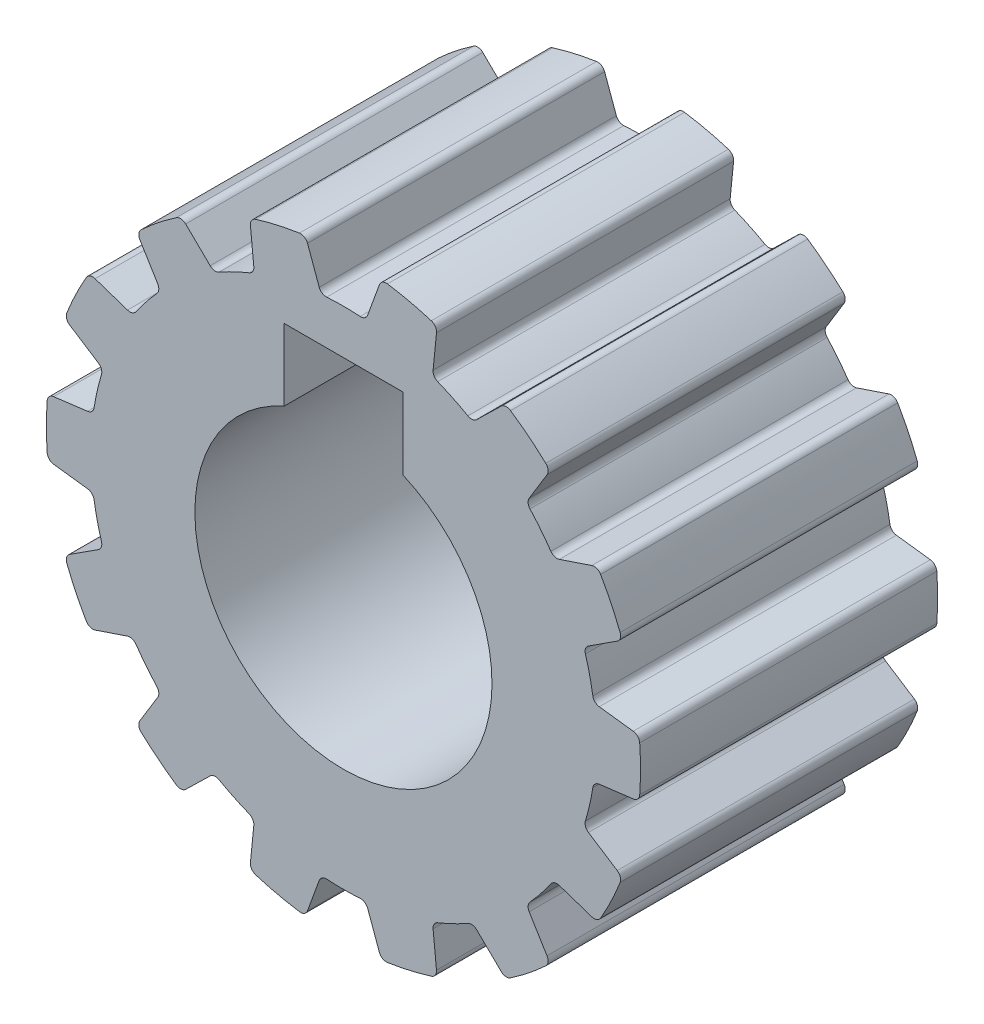
from build123d import *

# Parameters (mm, degrees)
SKETCH1_R           = 10
BOSS_EXTRUDE1_DEPTH = 10
CUT_EXTRUDE1_DEPTH  = 11
CIRPATTERN1_COUNT   = 14
FILLET1_R           = 0.25


with BuildPart() as part:
    # Sketch1 → Boss-Extrude1 (new body)
    with BuildSketch(Plane.XY):
        Circle(SKETCH1_R)
        with BuildLine():
            Line((-2, 7), (2, 7))
            Line((2, 7), (2, 4.582575695))
            ThreePointArc((2, 4.582575695), (0, -5), (-2, 4.582575695))
            Line((-2, 4.582575695), (-2, 7))
        make_face(mode=Mode.SUBTRACT)
    extrude(amount=BOSS_EXTRUDE1_DEPTH)

    # Sketch2 → Cut-Extrude1 (cut, through all)
    with BuildSketch(Plane.XY.offset(10)):
        with BuildLine():
            Line((0.75, 8.466847111), (1.278168411, 9.917977894))
            ThreePointArc((1.278168411, 9.917977894), (0, 10), (-1.278168411, 9.917977894))
            Line((-1.278168411, 9.917977894), (-0.75, 8.466847111))
            ThreePointArc((-0.75, 8.466847111), (0, 8.5), (0.75, 8.466847111))
        make_face()
    cut_extrude1 = extrude(amount=-CUT_EXTRUDE1_DEPTH, mode=Mode.SUBTRACT)

    # CirPattern1: Cut-Extrude1 ×14 about axis
    cirpattern1_axis = Axis((0, 0, 0), (0, 0, 1))
    for i in range(1, CIRPATTERN1_COUNT):
        add(cut_extrude1.rotate(cirpattern1_axis, i * 360 / CIRPATTERN1_COUNT), mode=Mode.SUBTRACT)

    # Fillet1
    fillet1_edges = [part.edges().sort_by_distance(p)[0] for p in [
        (-8.087674876, 2.615246661, 5),
        (-8.421456277, 1.152854793, 5),
        (-9.95373271, 0.960835643, 5),
        (-9.384894253, 3.453079765, 5),
        (-8.421456277, -1.152854793, 5),
        (-8.087674876, -2.615246661, 5),
        (-9.384894253, -3.453079765, 5),
        (-9.95373271, -0.960835643, 5),
        (-7.08726498, -4.692619216, 5),
        (-6.152030277, -5.865366439, 5),
        (-6.957262391, -7.183070376, 5),
        (-8.55111233, -5.184445768, 5),
        (-4.349353934, -7.302952852, 5),
        (-2.997900632, -7.953778461, 5),
        (-3.151659387, -9.490365805, 5),
        (-5.45483928, -8.381212826, 5),
        (-0.75, -8.466847111, 5),
        (0.75, -8.466847111, 5),
        (1.278168411, -9.917977894, 5),
        (-1.278168411, -9.917977894, 5),
        (2.997900632, -7.953778461, 5),
        (4.349353934, -7.302952852, 5),
        (5.45483928, -8.381212826, 5),
        (3.151659387, -9.490365805, 5),
        (6.152030277, -5.865366439, 5),
        (7.08726498, -4.692619216, 5),
        (8.55111233, -5.184445768, 5),
        (6.957262391, -7.183070376, 5),
        (8.087674876, -2.615246661, 5),
        (8.421456277, -1.152854793, 5),
        (9.95373271, -0.960835643, 5),
        (9.384894253, -3.453079765, 5),
        (8.421456277, 1.152854793, 5),
        (8.087674876, 2.615246661, 5),
        (9.384894253, 3.453079765, 5),
        (9.95373271, 0.960835643, 5),
        (7.08726498, 4.692619216, 5),
        (6.152030277, 5.865366439, 5),
        (6.957262391, 7.183070376, 5),
        (8.55111233, 5.184445768, 5),
        (4.349353934, 7.302952852, 5),
        (2.997900632, 7.953778461, 5),
        (3.151659387, 9.490365805, 5),
        (5.45483928, 8.381212826, 5),
        (-2.997900632, 7.953778461, 5),
        (-4.349353934, 7.302952852, 5),
        (-5.45483928, 8.381212826, 5),
        (-3.151659387, 9.490365805, 5),
        (0.75, 8.466847111, 5),
        (-0.75, 8.466847111, 5),
        (-1.278168411, 9.917977894, 5),
        (1.278168411, 9.917977894, 5),
        (-6.152030277, 5.865366439, 5),
        (-7.08726498, 4.692619216, 5),
        (-8.55111233, 5.184445768, 5),
        (-6.957262391, 7.183070376, 5),
    ]]
    fillet(fillet1_edges, radius=FILLET1_R)


solid = part.part
